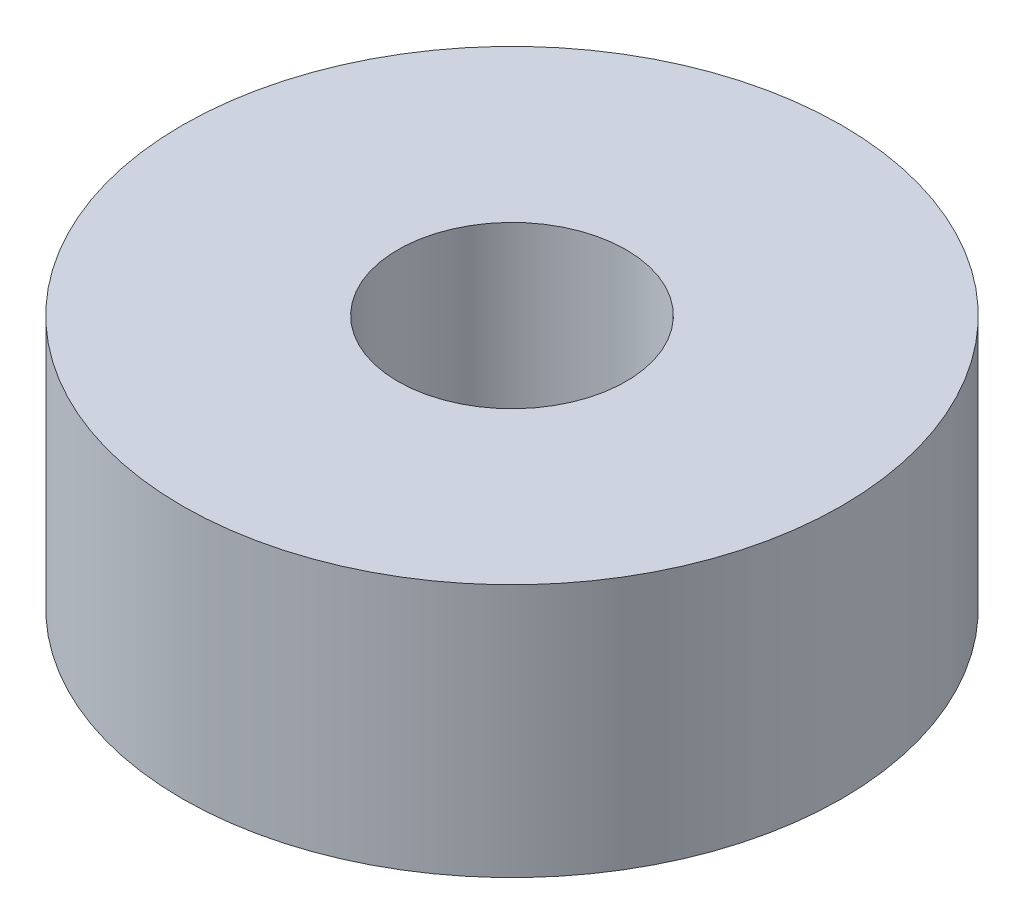
from build123d import *

# Parameters (mm, degrees)
SKETCH1_R           = 6.5
SKETCH1_R_2         = 2.25
BOSS_EXTRUDE1_DEPTH = 5


with BuildPart() as part:
    # Sketch1 → Boss-Extrude1 (new body)
    with BuildSketch(Plane(origin=(0, 0, 0), x_dir=(1, 0, 0), z_dir=(0, 1, 0))):
        Circle(SKETCH1_R)
        Circle(SKETCH1_R_2, mode=Mode.SUBTRACT)
    extrude(amount=BOSS_EXTRUDE1_DEPTH)


solid = part.part
